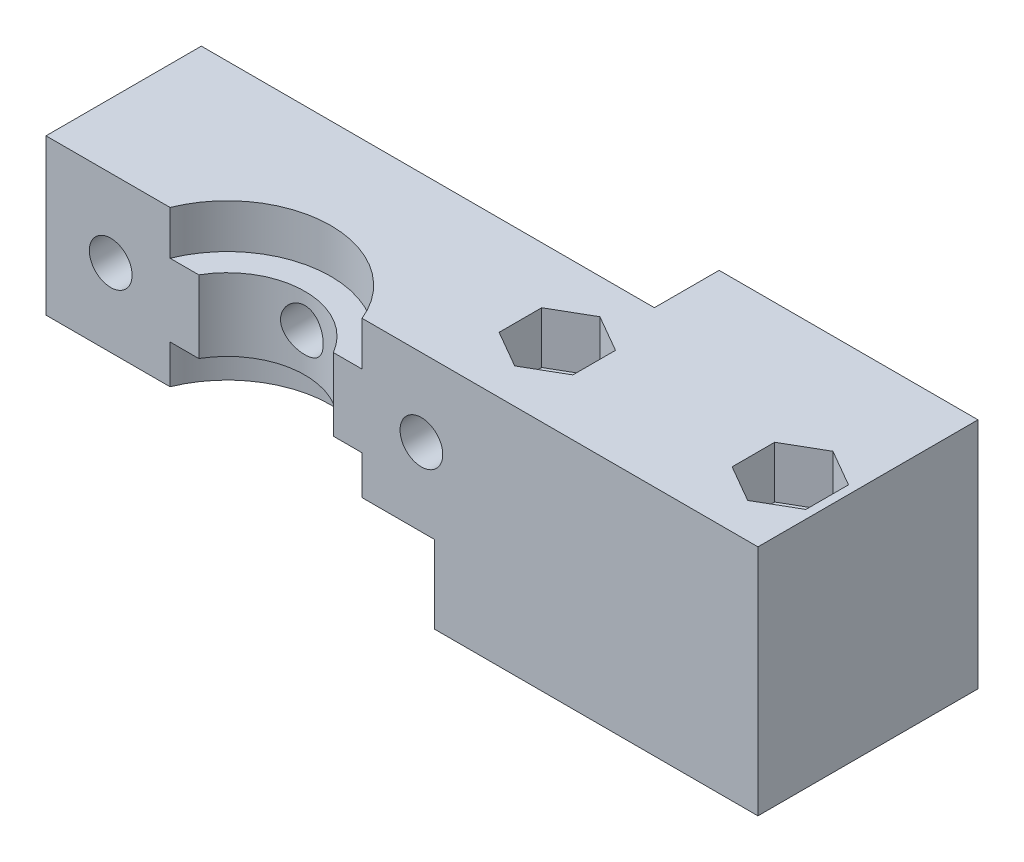
from build123d import *

# Parameters (mm, degrees)
EXTRUDE_1_DEPTH     = 3
EXTRUDE_2_DEPTH     = 5.6
EXTRUDE_3_DEPTH     = 3.4
SKETCH_5_W          = 25
SKETCH_5_H          = 12
EXTRUDE_4_DEPTH     = 18
SKETCH_8_W          = 20
SKETCH_8_H          = 18
EXTRUDE_5_DEPTH     = 5
SKETCH_4_R          = 1.65
CUT_EXTRUDE_1_DEPTH = 13
SKETCH_6_R          = 1.75
CUT_EXTRUDE_2_DEPTH = 19
CUT_EXTRUDE_3_DEPTH = 4


with BuildPart() as part:
    # 草图1 → 凸台-拉伸1 (new body)
    with BuildSketch(Plane(origin=(0, 0, 0), x_dir=(1, 0, 0), z_dir=(0, 1, 0))):
        with BuildLine():
            Line((17, 3), (17, 15))
            Line((17, 15), (-17, 15))
            Line((-17, 15), (-17, 3))
            Line((-17, 3), (-7.416198487, 3))
            ThreePointArc((-7.416198487, 3), (0, 8), (7.416198487, 3))
            Line((7.416198487, 3), (17, 3))
        make_face()
    extrude(amount=EXTRUDE_1_DEPTH)

    # 草图2 → 凸台-拉伸2 (add)
    with BuildSketch(Plane(origin=(0, 3, 0), x_dir=(1, 0, 0), z_dir=(0, 1, 0))):
        with BuildLine():
            Line((5.196152423, 3), (17, 3))
            Line((17, 3), (17, 15))
            Line((17, 15), (-17, 15))
            Line((-17, 15), (-17, 3))
            Line((-17, 3), (-5.196152423, 3))
            ThreePointArc((-5.196152423, 3), (0, 6), (5.196152423, 3))
        make_face()
    extrude(amount=EXTRUDE_2_DEPTH)

    # 草图3 → 凸台-拉伸3 (add)
    with BuildSketch(Plane(origin=(0, 8.6, 0), x_dir=(1, 0, 0), z_dir=(0, 1, 0))):
        with BuildLine():
            Line((-17, 3), (-7.416198487, 3))
            ThreePointArc((-7.416198487, 3), (0, 8), (7.416198487, 3))
            Line((7.416198487, 3), (17, 3))
            Line((17, 3), (17, 15))
            Line((17, 15), (-17, 15))
            Line((-17, 15), (-17, 3))
        make_face()
    extrude(amount=EXTRUDE_3_DEPTH)

    # 草图5 → 凸台-拉伸4 (add)
    with BuildSketch(Plane.XZ.offset(-12)):
        with Locations((25.5, -9)):
            Rectangle(SKETCH_5_W, SKETCH_5_H)
    extrude(amount=EXTRUDE_4_DEPTH)

    # 草图8 → 凸台-拉伸5 (add)
    with BuildSketch(Plane(origin=(0, 0, -15), x_dir=(-1, 0, 0), z_dir=(0, 0, -1))):
        with Locations((-28, 3)):
            Rectangle(SKETCH_8_W, SKETCH_8_H)
    extrude(amount=EXTRUDE_5_DEPTH)

    # 草图4 → 切除-拉伸1 (cut, through all)
    with BuildSketch(Plane.XY.offset(-15)):
        with Locations((-12, 6)):
            Circle(SKETCH_4_R)
        with Locations((12, 6)):
            Circle(SKETCH_4_R)
        with Locations((0, 6)):
            Circle(SKETCH_4_R)
    extrude(amount=CUT_EXTRUDE_1_DEPTH, mode=Mode.SUBTRACT)

    # 草图6 → 切除-拉伸2 (cut, through all)
    with BuildSketch(Plane.XZ.offset(6)):
        with Locations((16.5, -9)):
            Circle(SKETCH_6_R)
        with Locations((34.5, -9)):
            Circle(SKETCH_6_R)
    extrude(amount=-CUT_EXTRUDE_2_DEPTH, mode=Mode.SUBTRACT)

    # 草图7 → 切除-拉伸3 (cut)
    with BuildSketch(Plane(origin=(0, 12, 0), x_dir=(1, 0, 0), z_dir=(0, 1, 0))):
        Polygon((16.5, 5.709103466), (19.35, 7.354551733), (19.35, 10.645448267), (16.5, 12.290896534), (13.65, 10.645448267), (13.65, 7.354551733), align=None)
        Polygon((34.5, 5.709103466), (37.35, 7.354551733), (37.35, 10.645448267), (34.5, 12.290896534), (31.65, 10.645448267), (31.65, 7.354551733), align=None)
    extrude(amount=-CUT_EXTRUDE_3_DEPTH, mode=Mode.SUBTRACT)


solid = part.part
